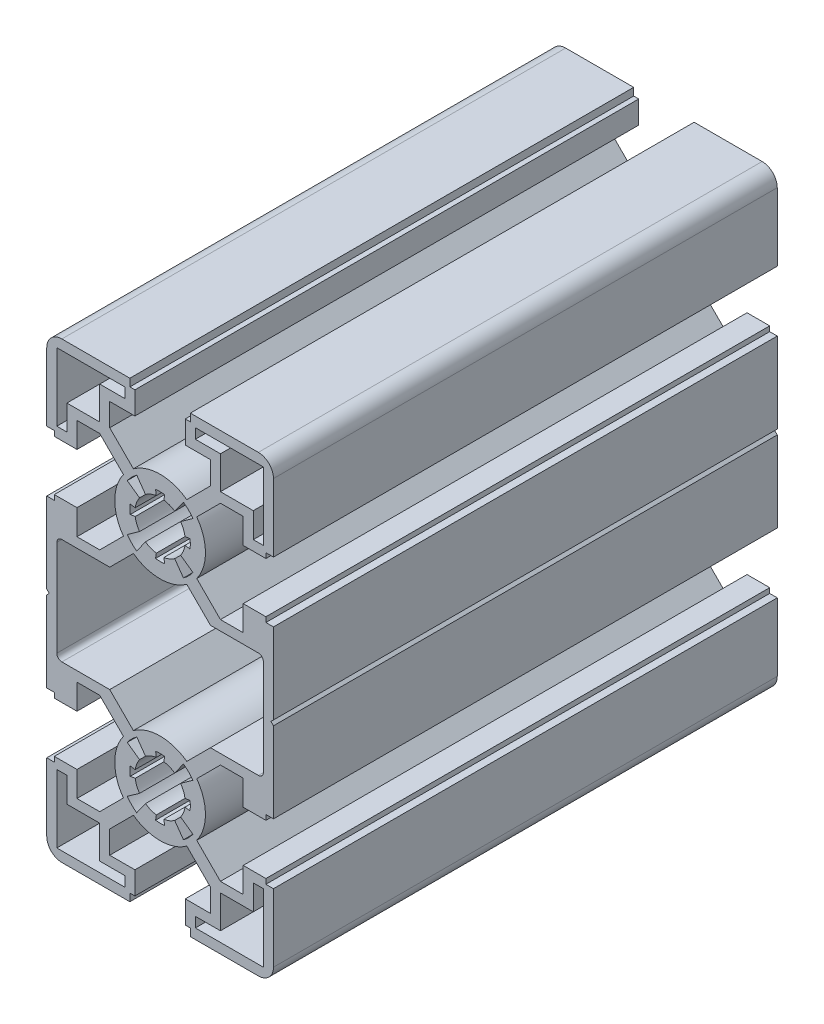
from build123d import *

# Parameters (mm, degrees)
Y_KSEKLIK_EKSTR_ZYON1_DEPTH = 100


with BuildPart() as part:
    # Çizim1 → Yükseklik-Ekstrüzyon1 (new body)
    with BuildSketch(Plane.XY.offset(100)):
        with BuildLine():
            Line((19.500000894, 45), (6.000000052, 45))
            Line((6.000000052, 45), (6.000000052, 43.49999696))
            Line((6.000000052, 43.49999696), (4.999999888, 43.49999696))
            Line((4.999999888, 43.49999696), (4.999999888, 38.999995988))
            Line((4.999999888, 38.999995988), (10.000004015, 38.999995988))
            Line((10.000004015, 38.999995988), (10.000004015, 34.479892375))
            Line((10.000004015, 34.479892375), (5.296548163, 29.776437378))
            ThreePointArc((5.296548163, 29.776437378), (3.069e-06, 31.499995302), (-5.296542053, 29.776437465))
            Line((-5.296542053, 29.776437465), (-9.999998172, 34.479892653))
            Line((-9.999998172, 34.479892653), (-9.999998172, 38.999995988))
            Line((-9.999998172, 38.999995988), (-4.999999888, 38.999995988))
            Line((-4.999999888, 38.999995988), (-4.999999888, 43.49999696))
            Line((-4.999999888, 43.49999696), (-6.000000052, 43.49999696))
            Line((-6.000000052, 43.49999696), (-6.000000052, 45))
            Line((-6.000000052, 45), (-19.500000894, 45))
            ThreePointArc((-19.500000894, 45), (-21.621321238, 44.121320344), (-22.500000894, 42))
            Line((-22.500000894, 42), (-22.500000894, 28.499996364))
            Line((-22.500000894, 28.499996364), (-20.999999717, 28.499996364))
            Line((-20.999999717, 28.499996364), (-20.999999717, 27.499998063))
            Line((-20.999999717, 27.499998063), (-16.499999911, 27.499998063))
            Line((-16.499999911, 27.499998063), (-16.499999911, 32.499992804))
            Line((-16.499999911, 32.499992804), (-11.979897772, 32.499992804))
            Line((-11.979897772, 32.499992804), (-7.276441388, 27.796537301))
            ThreePointArc((-7.276441388, 27.796537301), (-8.999997005, 22.499994159), (-7.276440043, 17.203451455))
            Line((-7.276440043, 17.203451455), (-11.979896129, 12.499996224))
            Line((-11.979896129, 12.499996224), (-16.499999911, 12.499996224))
            Line((-16.499999911, 12.499996224), (-16.499999911, 17.499996573))
            Line((-16.499999911, 17.499996573), (-20.999999717, 17.499996573))
            Line((-20.999999717, 17.499996573), (-20.999999717, 16.499998271))
            Line((-20.999999717, 16.499998271), (-22.500000894, 16.499998271))
            Line((-22.500000894, 16.499998271), (-22.500000894, 0.5))
            Line((-22.500000894, 0.5), (-22.000000894, 0))
            Line((-22.000000894, 0), (-22.500000894, -0.5))
            Line((-22.500000894, -0.5), (-22.500000894, -16.499998271))
            Line((-22.500000894, -16.499998271), (-20.999999717, -16.499998271))
            Line((-20.999999717, -16.499998271), (-20.999999717, -17.499996573))
            Line((-20.999999717, -17.499996573), (-16.499999911, -17.499996573))
            Line((-16.499999911, -17.499996573), (-16.499999911, -12.50000228))
            Line((-16.499999911, -12.50000228), (-11.979896129, -12.50000228))
            Line((-11.979896129, -12.50000228), (-7.276440194, -17.203457479))
            ThreePointArc((-7.276440194, -17.203457479), (-8.99999712, -22.499999355), (-7.276442454, -27.796541967))
            Line((-7.276442454, -27.796541967), (-11.979899369, -32.49999702))
            Line((-11.979899369, -32.49999702), (-16.499999911, -32.49999702))
            Line((-16.499999911, -32.49999702), (-16.499999911, -27.499998063))
            Line((-16.499999911, -27.499998063), (-20.999999717, -27.499998063))
            Line((-20.999999717, -27.499998063), (-20.999999717, -28.499996364))
            Line((-20.999999717, -28.499996364), (-22.500000894, -28.499996364))
            Line((-22.500000894, -28.499996364), (-22.500000894, -42))
            ThreePointArc((-22.500000894, -42), (-21.621321238, -44.121320344), (-19.500000894, -45))
            Line((-19.500000894, -45), (-6.000000052, -45))
            Line((-6.000000052, -45), (-6.000000052, -43.49999696))
            Line((-6.000000052, -43.49999696), (-4.999999888, -43.49999696))
            Line((-4.999999888, -43.49999696), (-4.999999888, -39.000002045))
            Line((-4.999999888, -39.000002045), (-9.999998172, -39.000002045))
            Line((-9.999998172, -39.000002045), (-9.999998172, -34.479898709))
            Line((-9.999998172, -34.479898709), (-5.296542053, -29.776443522))
            ThreePointArc((-5.296542053, -29.776443522), (2.88e-06, -31.500001275), (5.296547814, -29.776443522))
            Line((5.296547814, -29.776443522), (10.000004015, -34.479898987))
            Line((10.000004015, -34.479898987), (10.000004015, -39.000002045))
            Line((10.000004015, -39.000002045), (4.999999888, -39.000002045))
            Line((4.999999888, -39.000002045), (4.999999888, -43.49999696))
            Line((4.999999888, -43.49999696), (6.000000052, -43.49999696))
            Line((6.000000052, -43.49999696), (6.000000052, -45))
            Line((6.000000052, -45), (19.500000894, -45))
            ThreePointArc((19.500000894, -45), (21.621321238, -44.121320344), (22.500000894, -42))
            Line((22.500000894, -42), (22.500000894, -28.499996364))
            Line((22.500000894, -28.499996364), (20.999999717, -28.499996364))
            Line((20.999999717, -28.499996364), (20.999999717, -27.499998063))
            Line((20.999999717, -27.499998063), (16.499999911, -27.499998063))
            Line((16.499999911, -27.499998063), (16.499999911, -32.49999702))
            Line((16.499999911, -32.49999702), (11.979899369, -32.49999702))
            Line((11.979899369, -32.49999702), (7.276446369, -27.796544502))
            ThreePointArc((7.276446369, -27.796544502), (9.000002881, -22.500001111), (7.276446176, -17.203457782))
            Line((7.276446176, -17.203457782), (11.979902609, -12.50000228))
            Line((11.979902609, -12.50000228), (16.499999911, -12.50000228))
            Line((16.499999911, -12.50000228), (16.499999911, -17.499996573))
            Line((16.499999911, -17.499996573), (20.999999717, -17.499996573))
            Line((20.999999717, -17.499996573), (20.999999717, -16.499998271))
            Line((20.999999717, -16.499998271), (22.500000894, -16.499998271))
            Line((22.500000894, -16.499998271), (22.500000894, -0.5))
            Line((22.500000894, -0.5), (22.000000894, 0))
            Line((22.000000894, 0), (22.500000894, 0.5))
            Line((22.500000894, 0.5), (22.500000894, 16.499998271))
            Line((22.500000894, 16.499998271), (20.999999717, 16.499998271))
            Line((20.999999717, 16.499998271), (20.999999717, 17.499996573))
            Line((20.999999717, 17.499996573), (16.499999911, 17.499996573))
            Line((16.499999911, 17.499996573), (16.499999911, 12.499996224))
            Line((16.499999911, 12.499996224), (11.979902609, 12.499996224))
            Line((11.979902609, 12.499996224), (7.276446207, 17.203451695))
            ThreePointArc((7.276446207, 17.203451695), (9.000002995, 22.499995326), (7.276446179, 27.796538948))
            Line((7.276446179, 27.796538948), (11.979900967, 32.499992804))
            Line((11.979900967, 32.499992804), (16.499999911, 32.499992804))
            Line((16.499999911, 32.499992804), (16.499999911, 27.499998063))
            Line((16.499999911, 27.499998063), (20.999999717, 27.499998063))
            Line((20.999999717, 27.499998063), (20.999999717, 28.499996364))
            Line((20.999999717, 28.499996364), (22.500000894, 28.499996364))
            Line((22.500000894, 28.499996364), (22.500000894, 42))
            ThreePointArc((22.500000894, 42), (21.621321238, 44.121320344), (19.500000894, 45))
        make_face()
        with BuildLine():
            Line((-0.89928026, -28.43222597), (-0.749399737, -27.443521854))
            ThreePointArc((-0.749399737, -27.443521854), (-1.874243748, -27.135430012), (-2.89711415, -26.575134759))
            Line((-2.89711415, -26.575134759), (-4.635384368, -29.020214849))
            ThreePointArc((-4.635384368, -29.020214849), (-5.656851062, -28.156855832), (-6.52021019, -27.135389232))
            Line((-6.52021019, -27.135389232), (-4.075130289, -25.397118748))
            ThreePointArc((-4.075130289, -25.397118748), (-4.635425755, -24.374248155), (-4.943517699, -23.249403892))
            Line((-4.943517699, -23.249403892), (-5.932221815, -23.399284416))
            ThreePointArc((-5.932221815, -23.399284416), (-5.99999712, -22.500001275), (-5.932221815, -21.600718134))
            Line((-5.932221815, -21.600718134), (-4.943517699, -21.750598657))
            ThreePointArc((-4.943517699, -21.750598657), (-4.635425857, -20.625754647), (-4.075130603, -19.602884244))
            Line((-4.075130603, -19.602884244), (-6.520210694, -17.864614026))
            ThreePointArc((-6.520210694, -17.864614026), (-5.656851676, -16.843147333), (-4.635385077, -15.979788204))
            Line((-4.635385077, -15.979788204), (-2.897114593, -18.424868106))
            ThreePointArc((-2.897114593, -18.424868106), (-1.874243999, -17.86457264), (-0.749399737, -17.556480696))
            Line((-0.749399737, -17.556480696), (-0.89928026, -16.56777658))
            ThreePointArc((-0.89928026, -16.56777658), (2.88e-06, -16.500001275), (0.899286021, -16.56777658))
            Line((0.899286021, -16.56777658), (0.749405498, -17.556480696))
            ThreePointArc((0.749405498, -17.556480696), (1.874249508, -17.864572538), (2.897119911, -18.424867791))
            Line((2.897119911, -18.424867791), (4.635390129, -15.979787701))
            ThreePointArc((4.635390129, -15.979787701), (5.656856823, -16.843146718), (6.520215951, -17.864613318))
            Line((6.520215951, -17.864613318), (4.07513605, -19.602883802))
            ThreePointArc((4.07513605, -19.602883802), (4.635431516, -20.625754395), (4.94352346, -21.750598657))
            Line((4.94352346, -21.750598657), (5.932227575, -21.600718134))
            ThreePointArc((5.932227575, -21.600718134), (6.00000288, -22.500001275), (5.932227575, -23.399284416))
            Line((5.932227575, -23.399284416), (4.94352346, -23.249403892))
            ThreePointArc((4.94352346, -23.249403892), (4.635431618, -24.374247903), (4.075136364, -25.397118305))
            Line((4.075136364, -25.397118305), (6.520216455, -27.135388524))
            ThreePointArc((6.520216455, -27.135388524), (5.656857437, -28.156855217), (4.635390837, -29.020214346))
            Line((4.635390837, -29.020214346), (2.897120354, -26.575134444))
            ThreePointArc((2.897120354, -26.575134444), (1.87424976, -27.13542991), (0.749405498, -27.443521854))
            Line((0.749405498, -27.443521854), (0.899286021, -28.43222597))
            ThreePointArc((0.899286021, -28.43222597), (2.88e-06, -28.500001275), (-0.89928026, -28.43222597))
        make_face(mode=Mode.SUBTRACT)
        Polygon((-18.500103663, 29.50010271), (-20.500100266, 29.50010271), (-20.500100266, 43.000100266), (-7.00010271, 43.000100266), (-7.00010271, 41.000103663), (-11.98, 41.000103663), (-11.98, 34.48), (-18.500103663, 34.48), align=None, mode=Mode.SUBTRACT)
        Polygon((18.500100869, -29.500100847), (20.500101197, -29.500100847), (20.500101197, -43.000101197), (7.000100847, -43.000101197), (7.000100847, -41.000100869), (11.98, -41.000100869), (11.98, -34.48), (18.500100869, -34.48), align=None, mode=Mode.SUBTRACT)
        Polygon((7.000100847, 41.000103663), (7.000100847, 43.000100266), (20.500101197, 43.000100266), (20.500101197, 29.50010271), (18.500100869, 29.50010271), (18.500100869, 34.48), (11.98, 34.48), (11.98, 41.000103663), align=None, mode=Mode.SUBTRACT)
        Polygon((-7.00010271, -41.000100869), (-7.00010271, -43.000101197), (-20.500100266, -43.000101197), (-20.500100266, -29.500100847), (-18.500103663, -29.500100847), (-18.500103663, -34.48), (-11.98, -34.48), (-11.98, -41.000100869), align=None, mode=Mode.SUBTRACT)
        with BuildLine():
            Line((-20.499997341, -9.520103353), (-20.499997341, 9.520097893))
            ThreePointArc((-20.499997341, 9.520097893), (-20.207104122, 10.227204674), (-19.499997341, 10.520097893))
            Line((-19.499997341, 10.520097893), (-9.999998297, 10.520097893))
            Line((-9.999998297, 10.520097893), (-5.296542092, 15.223553167))
            ThreePointArc((-5.296542092, 15.223553167), (1.928e-06, 13.499995302), (5.296546357, 15.223551911))
            Line((5.296546357, 15.223551911), (10.000001256, 10.520097893))
            Line((10.000001256, 10.520097893), (19.500003792, 10.520097893))
            ThreePointArc((19.500003792, 10.520097893), (20.207110573, 10.227204674), (20.500003792, 9.520097893))
            Line((20.500003792, 9.520097893), (20.500003792, -9.520103353))
            ThreePointArc((20.500003792, -9.520103353), (20.207110573, -10.227210134), (19.500003792, -10.520103353))
            Line((19.500003792, -10.520103353), (10.000003002, -10.520103353))
            Line((10.000003002, -10.520103353), (5.296546454, -15.223558038))
            ThreePointArc((5.296546454, -15.223558038), (2.633e-06, -13.500001275), (-5.296541093, -15.223558329))
            Line((-5.296541093, -15.223558329), (-9.999996551, -10.520103353))
            Line((-9.999996551, -10.520103353), (-19.499997341, -10.520103353))
            ThreePointArc((-19.499997341, -10.520103353), (-20.207104122, -10.227210134), (-20.499997341, -9.520103353))
        make_face(mode=Mode.SUBTRACT)
        with BuildLine():
            Line((-0.899280146, 16.567770607), (-0.74939926, 17.556477114))
            ThreePointArc((-0.74939926, 17.556477114), (-1.874242726, 17.864568807), (-2.897112634, 18.42486379))
            Line((-2.897112634, 18.42486379), (-4.635385337, 15.979780204))
            ThreePointArc((-4.635385337, 15.979780204), (-5.65685227, 16.843139423), (-6.5202116, 17.864606261))
            Line((-6.5202116, 17.864606261), (-4.075128203, 19.60287923))
            ThreePointArc((-4.075128203, 19.60287923), (-4.635423398, 20.625749329), (-4.943515193, 21.750593047))
            Line((-4.943515193, 21.750593047), (-5.9322217, 21.600712161))
            ThreePointArc((-5.9322217, 21.600712161), (-5.999997005, 22.499995302), (-5.9322217, 23.399278443))
            Line((-5.9322217, 23.399278443), (-4.943515193, 23.249397557))
            ThreePointArc((-4.943515193, 23.249397557), (-4.6354235, 24.374241023), (-4.075128517, 25.397110931))
            Line((-4.075128517, 25.397110931), (-6.520212103, 27.135383634))
            ThreePointArc((-6.520212103, 27.135383634), (-5.656852884, 28.156850567), (-4.635386046, 29.020209897))
            Line((-4.635386046, 29.020209897), (-2.897113077, 26.5751265))
            ThreePointArc((-2.897113077, 26.5751265), (-1.874242978, 27.135421695), (-0.74939926, 27.443513489))
            Line((-0.74939926, 27.443513489), (-0.899280146, 28.432219997))
            ThreePointArc((-0.899280146, 28.432219997), (2.995e-06, 28.499995302), (0.899286136, 28.432219997))
            Line((0.899286136, 28.432219997), (0.74940525, 27.443513489))
            ThreePointArc((0.74940525, 27.443513489), (1.874248716, 27.135421797), (2.897118624, 26.575126814))
            Line((2.897118624, 26.575126814), (4.635391327, 29.0202104))
            ThreePointArc((4.635391327, 29.0202104), (5.65685826, 28.156851181), (6.52021759, 27.135384343))
            Line((6.52021759, 27.135384343), (4.075134193, 25.397111374))
            ThreePointArc((4.075134193, 25.397111374), (4.635429388, 24.374241275), (4.943521182, 23.249397557))
            Line((4.943521182, 23.249397557), (5.93222769, 23.399278443))
            ThreePointArc((5.93222769, 23.399278443), (6.000002995, 22.499995302), (5.93222769, 21.600712161))
            Line((5.93222769, 21.600712161), (4.943521182, 21.750593047))
            ThreePointArc((4.943521182, 21.750593047), (4.63542949, 20.625749581), (4.075134507, 19.602879673))
            Line((4.075134507, 19.602879673), (6.520218093, 17.86460697))
            ThreePointArc((6.520218093, 17.86460697), (5.656858874, 16.843140037), (4.635392036, 15.979780707))
            Line((4.635392036, 15.979780707), (2.897119067, 18.424864104))
            ThreePointArc((2.897119067, 18.424864104), (1.874248968, 17.864568909), (0.74940525, 17.556477114))
            Line((0.74940525, 17.556477114), (0.899286136, 16.567770607))
            ThreePointArc((0.899286136, 16.567770607), (2.995e-06, 16.499995302), (-0.899280146, 16.567770607))
        make_face(mode=Mode.SUBTRACT)
    extrude(amount=-Y_KSEKLIK_EKSTR_ZYON1_DEPTH)


solid = part.part
